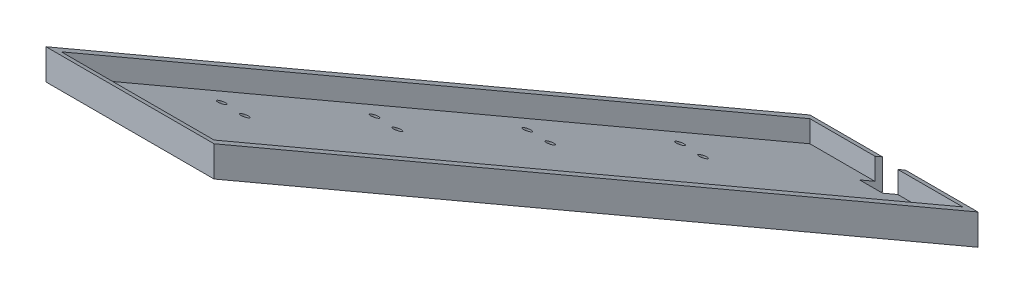
from build123d import *

# Parameters (mm, degrees)
BOSS_EXTRUDE1_DEPTH = 110
CUT_EXTRUDE1_DEPTH  = 100
SKETCH4_W           = 15
SKETCH4_H           = 30
CUT_EXTRUDE2_DEPTH  = 90
SKETCH7_R           = 2.5
CUT_EXTRUDE3_DEPTH  = 413


with BuildPart() as part:
    # Sketch1 → Boss-Extrude1 (new body)
    with BuildSketch(Plane(origin=(0, 0, 0), x_dir=(0, 0, -1), z_dir=(1, 0, 0))):
        Polygon((0, 20), (-500, 308.675134595), (-500, 288.675134595), (0, 0), align=None)
    extrude(amount=BOSS_EXTRUDE1_DEPTH)

    # Sketch3 → Cut-Extrude1 (cut)
    with BuildSketch(Plane(origin=(5, 0, 0), x_dir=(0, 0, -1), z_dir=(1, 0, 0))):
        Polygon((-495, 291.561885941), (-5, 8.660254038), (-5, 22.886751346), (-495, 305.788383249), align=None)
    extrude(amount=CUT_EXTRUDE1_DEPTH, mode=Mode.SUBTRACT)

    # Sketch4 → Cut-Extrude2 (cut)
    with BuildSketch(Plane(origin=(0, 0, 0), x_dir=(1, 0, 0), z_dir=(0, 1, 0))):
        with Locations((55, 0)):
            Rectangle(SKETCH4_W, SKETCH4_H)
    extrude(amount=CUT_EXTRUDE2_DEPTH, mode=Mode.SUBTRACT)

    # Sketch7 → Cut-Extrude3 (cut)
    with BuildSketch(Plane(origin=(0, 0, 0), x_dir=(1, 0, 0), z_dir=(0, 1, 0))):
        with Locations((20, -105)):
            Circle(SKETCH7_R)
        with Locations((90, -105)):
            Circle(SKETCH7_R)
        with Locations((20, -205)):
            Circle(SKETCH7_R)
        with Locations((20, -305)):
            Circle(SKETCH7_R)
        with Locations((20, -405)):
            Circle(SKETCH7_R)
        with Locations((35, -205)):
            Circle(SKETCH7_R)
        with Locations((35, -305)):
            Circle(SKETCH7_R)
        with Locations((35, -405)):
            Circle(SKETCH7_R)
        with Locations((35, -105)):
            Circle(SKETCH7_R)
        with Locations((90, -205)):
            Circle(SKETCH7_R)
        with Locations((90, -305)):
            Circle(SKETCH7_R)
        with Locations((90, -405)):
            Circle(SKETCH7_R)
        with Locations((75, -205)):
            Circle(SKETCH7_R)
        with Locations((75, -305)):
            Circle(SKETCH7_R)
        with Locations((75, -405)):
            Circle(SKETCH7_R)
        with Locations((75, -105)):
            Circle(SKETCH7_R)
    extrude(amount=CUT_EXTRUDE3_DEPTH, mode=Mode.SUBTRACT)


solid = part.part
